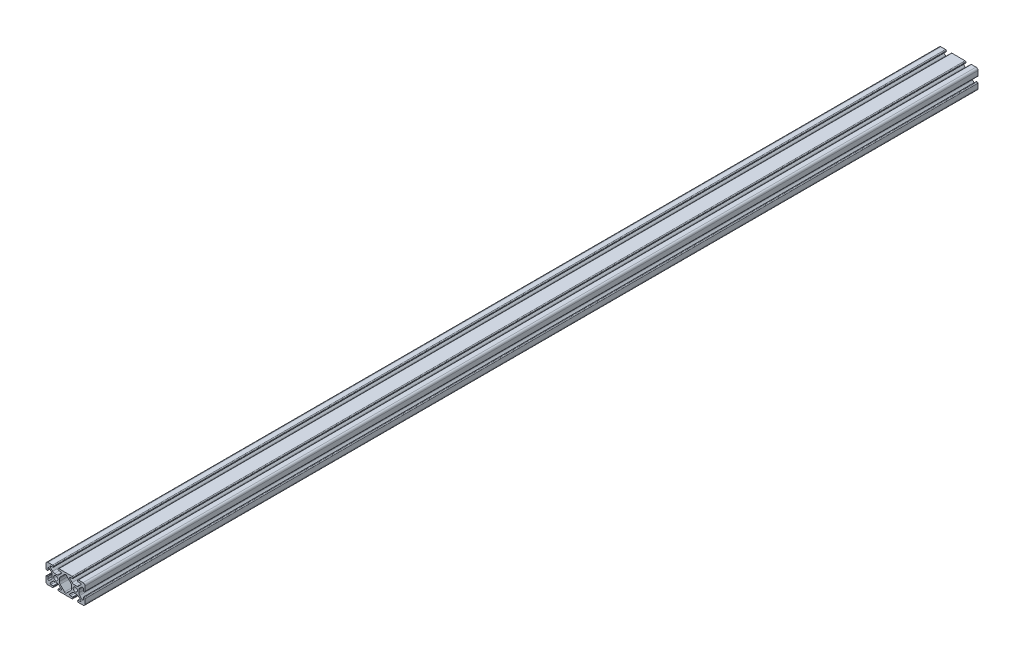
from build123d import *

# Parameters (mm, degrees)
SKETCH1_R           = 2.1463
BOSS_EXTRUDE1_DEPTH = 457.2


with BuildPart() as part:
    # Sketch1 → Boss-Extrude1 (new body, symmetric)
    with BuildSketch(Plane.XY):
        with BuildLine():
            Line((-19.9898, 7.9883), (-19.9898, 3.2893))
            ThreePointArc((-19.9898, 3.2893), (-19.75917588, 2.73252412), (-19.2024, 2.5019))
            Line((-19.2024, 2.5019), (-18.4912, 2.5019))
            ThreePointArc((-18.4912, 2.5019), (-18.275673853, 2.591173853), (-18.1864, 2.8067))
            Line((-18.1864, 2.8067), (-18.1864, 4.9149))
            ThreePointArc((-18.1864, 4.9149), (-17.668965253, 5.689295824), (-16.755503096, 5.507596904))
            Line((-16.755503096, 5.507596904), (-14.500665747, 3.252759555))
            ThreePointArc((-14.500665747, 3.252759555), (-13.850954457, 2.280397894), (-13.622806192, 1.133419111))
            Line((-13.622806192, 1.133419111), (-13.622806192, -1.133419111))
            ThreePointArc((-13.622806192, -1.133419111), (-13.850954457, -2.280397894), (-14.500665747, -3.252759555))
            Line((-14.500665747, -3.252759555), (-16.755503096, -5.507596904))
            ThreePointArc((-16.755503096, -5.507596904), (-17.668965253, -5.689295824), (-18.1864, -4.9149))
            Line((-18.1864, -4.9149), (-18.1864, -2.8067))
            ThreePointArc((-18.1864, -2.8067), (-18.275673853, -2.591173853), (-18.4912, -2.5019))
            Line((-18.4912, -2.5019), (-19.2024, -2.5019))
            ThreePointArc((-19.2024, -2.5019), (-19.75917588, -2.73252412), (-19.9898, -3.2893))
            Line((-19.9898, -3.2893), (-19.9898, -7.9883))
            ThreePointArc((-19.9898, -7.9883), (-19.402080467, -9.407180467), (-17.9832, -9.9949))
            Line((-17.9832, -9.9949), (-13.2842, -9.9949))
            ThreePointArc((-13.2842, -9.9949), (-12.72742412, -9.76427588), (-12.4968, -9.2075))
            Line((-12.4968, -9.2075), (-12.4968, -8.4963))
            ThreePointArc((-12.4968, -8.4963), (-12.586073853, -8.280773853), (-12.8016, -8.1915))
            Line((-12.8016, -8.1915), (-14.9098, -8.1915))
            ThreePointArc((-14.9098, -8.1915), (-15.684195824, -7.674065253), (-15.502496904, -6.760603096))
            Line((-15.502496904, -6.760603096), (-13.247659555, -4.505765747))
            ThreePointArc((-13.247659555, -4.505765747), (-12.275297894, -3.856054457), (-11.128319111, -3.627906192))
            Line((-11.128319111, -3.627906192), (-8.861480889, -3.627906192))
            ThreePointArc((-8.861480889, -3.627906192), (-7.714502106, -3.856054457), (-6.742140445, -4.505765747))
            Line((-6.742140445, -4.505765747), (-4.487303096, -6.760603096))
            ThreePointArc((-4.487303096, -6.760603096), (-4.305604176, -7.674065253), (-5.08, -8.1915))
            Line((-5.08, -8.1915), (-7.1882, -8.1915))
            ThreePointArc((-7.1882, -8.1915), (-7.403726147, -8.280773853), (-7.493, -8.4963))
            Line((-7.493, -8.4963), (-7.493, -9.2075))
            ThreePointArc((-7.493, -9.2075), (-7.26237588, -9.76427588), (-6.7056, -9.9949))
            Line((-6.7056, -9.9949), (0, -9.9949))
            Line((0, -9.9949), (6.7056, -9.9949))
            ThreePointArc((6.7056, -9.9949), (7.26237588, -9.76427588), (7.493, -9.2075))
            Line((7.493, -9.2075), (7.493, -8.4963))
            ThreePointArc((7.493, -8.4963), (7.403726147, -8.280773853), (7.1882, -8.1915))
            Line((7.1882, -8.1915), (5.08, -8.1915))
            ThreePointArc((5.08, -8.1915), (4.305604176, -7.674065253), (4.487303096, -6.760603096))
            Line((4.487303096, -6.760603096), (6.742140445, -4.505765747))
            ThreePointArc((6.742140445, -4.505765747), (7.714502106, -3.856054457), (8.861480889, -3.627906192))
            Line((8.861480889, -3.627906192), (11.128319111, -3.627906192))
            ThreePointArc((11.128319111, -3.627906192), (12.275297894, -3.856054457), (13.247659555, -4.505765747))
            Line((13.247659555, -4.505765747), (15.502496904, -6.760603096))
            ThreePointArc((15.502496904, -6.760603096), (15.684195824, -7.674065253), (14.9098, -8.1915))
            Line((14.9098, -8.1915), (12.8016, -8.1915))
            ThreePointArc((12.8016, -8.1915), (12.586073853, -8.280773853), (12.4968, -8.4963))
            Line((12.4968, -8.4963), (12.4968, -9.2075))
            ThreePointArc((12.4968, -9.2075), (12.72742412, -9.76427588), (13.2842, -9.9949))
            Line((13.2842, -9.9949), (17.9832, -9.9949))
            ThreePointArc((17.9832, -9.9949), (19.402080467, -9.407180467), (19.9898, -7.9883))
            Line((19.9898, -7.9883), (19.9898, -3.2893))
            ThreePointArc((19.9898, -3.2893), (19.75917588, -2.73252412), (19.2024, -2.5019))
            Line((19.2024, -2.5019), (18.4912, -2.5019))
            ThreePointArc((18.4912, -2.5019), (18.275673853, -2.591173853), (18.1864, -2.8067))
            Line((18.1864, -2.8067), (18.1864, -4.9149))
            ThreePointArc((18.1864, -4.9149), (17.668965253, -5.689295824), (16.755503096, -5.507596904))
            Line((16.755503096, -5.507596904), (14.500665747, -3.252759555))
            ThreePointArc((14.500665747, -3.252759555), (13.850954457, -2.280397894), (13.622806192, -1.133419111))
            Line((13.622806192, -1.133419111), (13.622806192, 1.133419111))
            ThreePointArc((13.622806192, 1.133419111), (13.850954457, 2.280397894), (14.500665747, 3.252759555))
            Line((14.500665747, 3.252759555), (16.755503096, 5.507596904))
            ThreePointArc((16.755503096, 5.507596904), (17.668965253, 5.689295824), (18.1864, 4.9149))
            Line((18.1864, 4.9149), (18.1864, 2.8067))
            ThreePointArc((18.1864, 2.8067), (18.275673853, 2.591173853), (18.4912, 2.5019))
            Line((18.4912, 2.5019), (19.2024, 2.5019))
            ThreePointArc((19.2024, 2.5019), (19.75917588, 2.73252412), (19.9898, 3.2893))
            Line((19.9898, 3.2893), (19.9898, 7.9883))
            ThreePointArc((19.9898, 7.9883), (19.402080467, 9.407180467), (17.9832, 9.9949))
            Line((17.9832, 9.9949), (13.2842, 9.9949))
            ThreePointArc((13.2842, 9.9949), (12.72742412, 9.76427588), (12.4968, 9.2075))
            Line((12.4968, 9.2075), (12.4968, 8.4963))
            ThreePointArc((12.4968, 8.4963), (12.586073853, 8.280773853), (12.8016, 8.1915))
            Line((12.8016, 8.1915), (14.9098, 8.1915))
            ThreePointArc((14.9098, 8.1915), (15.684195824, 7.674065253), (15.502496904, 6.760603096))
            Line((15.502496904, 6.760603096), (13.247659555, 4.505765747))
            ThreePointArc((13.247659555, 4.505765747), (12.275297894, 3.856054457), (11.128319111, 3.627906192))
            Line((11.128319111, 3.627906192), (8.861480889, 3.627906192))
            ThreePointArc((8.861480889, 3.627906192), (7.714502106, 3.856054457), (6.742140445, 4.505765747))
            Line((6.742140445, 4.505765747), (4.487303096, 6.760603096))
            ThreePointArc((4.487303096, 6.760603096), (4.305604176, 7.674065253), (5.08, 8.1915))
            Line((5.08, 8.1915), (7.1882, 8.1915))
            ThreePointArc((7.1882, 8.1915), (7.403726147, 8.280773853), (7.493, 8.4963))
            Line((7.493, 8.4963), (7.493, 9.2075))
            ThreePointArc((7.493, 9.2075), (7.26237588, 9.76427588), (6.7056, 9.9949))
            Line((6.7056, 9.9949), (0, 9.9949))
            Line((0, 9.9949), (-6.7056, 9.9949))
            ThreePointArc((-6.7056, 9.9949), (-7.26237588, 9.76427588), (-7.493, 9.2075))
            Line((-7.493, 9.2075), (-7.493, 8.4963))
            ThreePointArc((-7.493, 8.4963), (-7.403726147, 8.280773853), (-7.1882, 8.1915))
            Line((-7.1882, 8.1915), (-5.08, 8.1915))
            ThreePointArc((-5.08, 8.1915), (-4.305604176, 7.674065253), (-4.487303096, 6.760603096))
            Line((-4.487303096, 6.760603096), (-6.742140445, 4.505765747))
            ThreePointArc((-6.742140445, 4.505765747), (-7.714502106, 3.856054457), (-8.861480889, 3.627906192))
            Line((-8.861480889, 3.627906192), (-11.128319111, 3.627906192))
            ThreePointArc((-11.128319111, 3.627906192), (-12.275297894, 3.856054457), (-13.247659555, 4.505765747))
            Line((-13.247659555, 4.505765747), (-15.502496904, 6.760603096))
            ThreePointArc((-15.502496904, 6.760603096), (-15.684195824, 7.674065253), (-14.9098, 8.1915))
            Line((-14.9098, 8.1915), (-12.8016, 8.1915))
            ThreePointArc((-12.8016, 8.1915), (-12.586073853, 8.280773853), (-12.4968, 8.4963))
            Line((-12.4968, 8.4963), (-12.4968, 9.2075))
            ThreePointArc((-12.4968, 9.2075), (-12.72742412, 9.76427588), (-13.2842, 9.9949))
            Line((-13.2842, 9.9949), (-17.9832, 9.9949))
            ThreePointArc((-17.9832, 9.9949), (-19.402080467, 9.407180467), (-19.9898, 7.9883))
        make_face()
        with Locations((-9.9949, 0)):
            Circle(SKETCH1_R, mode=Mode.SUBTRACT)
        with Locations((9.9949, 0)):
            Circle(SKETCH1_R, mode=Mode.SUBTRACT)
        with BuildLine():
            Line((-6.366993808, 1.133419111), (-6.366993808, -1.133419111))
            ThreePointArc((-6.366993808, -1.133419111), (-6.138845543, -2.280397894), (-5.489134253, -3.252759555))
            Line((-5.489134253, -3.252759555), (-0.939581002, -7.802312806))
            ThreePointArc((-0.939581002, -7.802312806), (0, -8.1915), (0.939581002, -7.802312806))
            Line((0.939581002, -7.802312806), (5.489134253, -3.252759555))
            ThreePointArc((5.489134253, -3.252759555), (6.138845543, -2.280397894), (6.366993808, -1.133419111))
            Line((6.366993808, -1.133419111), (6.366993808, 1.133419111))
            ThreePointArc((6.366993808, 1.133419111), (6.138845543, 2.280397894), (5.489134253, 3.252759555))
            Line((5.489134253, 3.252759555), (0.939581002, 7.802312806))
            ThreePointArc((0.939581002, 7.802312806), (0, 8.1915), (-0.939581002, 7.802312806))
            Line((-0.939581002, 7.802312806), (-5.489134253, 3.252759555))
            ThreePointArc((-5.489134253, 3.252759555), (-6.138845543, 2.280397894), (-6.366993808, 1.133419111))
        make_face(mode=Mode.SUBTRACT)
    extrude(amount=BOSS_EXTRUDE1_DEPTH, both=True)


solid = part.part
